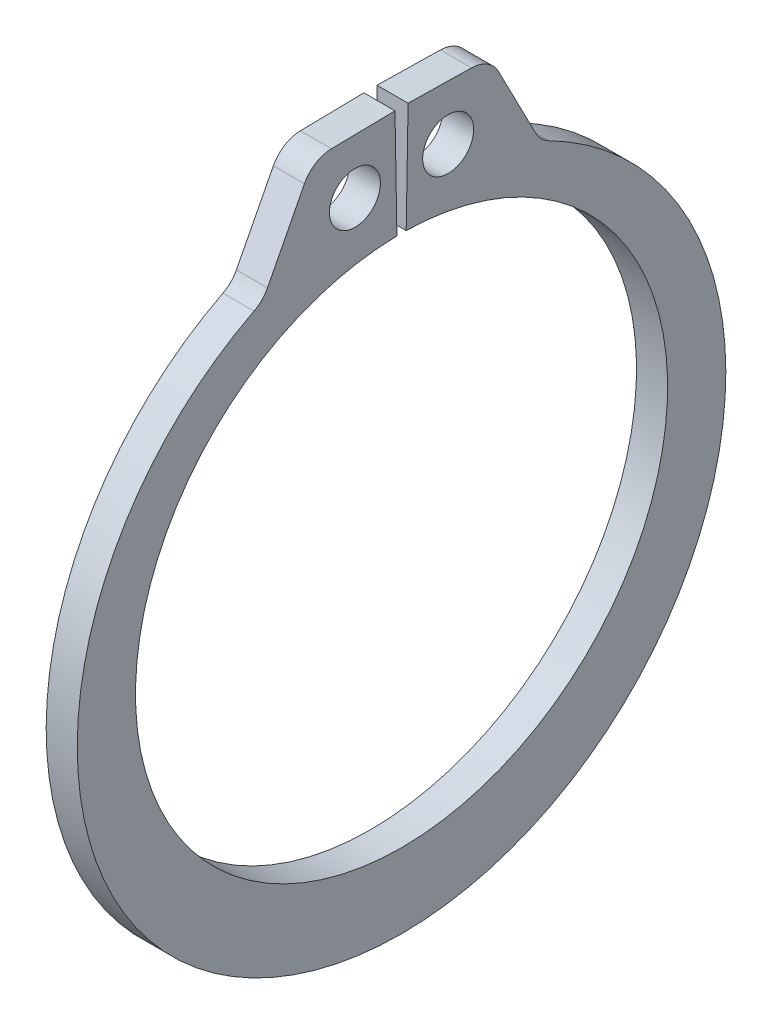
from build123d import *

# Parameters (mm, degrees)
SKETCH1_R      = 0.5207
EXTRUDE1_DEPTH = 0.3175
FILLET1_R      = 0.635


with BuildPart() as part:
    # Sketch1 → Extrude1 (new, symmetric)
    with BuildSketch(Plane(origin=(0, 0, 0), x_dir=(0, 0, -1), z_dir=(1, 0, 0))):
        with BuildLine():
            Line((-0.0948643, 5.434772132), (-0.133873919, 7.6696317))
            Line((-0.133873919, 7.6696317), (-1.810018595, 7.640374486))
            Line((-1.810018595, 7.640374486), (-2.834582122, 5.653822543))
            ThreePointArc((-2.834582122, 5.653822543), (0, -6.9596), (2.834582122, 5.653822543))
            Line((2.834582122, 5.653822543), (1.810018595, 7.640374486))
            Line((1.810018595, 7.640374486), (0.133873919, 7.6696317))
            Line((0.133873919, 7.6696317), (0.0948643, 5.434772132))
            ThreePointArc((0.0948643, 5.434772132), (0, -5.4356), (-0.0948643, 5.434772132))
        make_face()
        with Locations((-0.952441448, 6.537573309)):
            Circle(SKETCH1_R, mode=Mode.SUBTRACT)
        with Locations((0.952441448, 6.537573309)):
            Circle(SKETCH1_R, mode=Mode.SUBTRACT)
    extrude(amount=EXTRUDE1_DEPTH, both=True)

    # Fillet1
    fillet1_edges = [part.edges().sort_by_distance(p)[0] for p in [
        (0, 7.640374486, -1.810018595),
        (0, 5.653822543, -2.834582122),
        (0, 5.653822543, 2.834582122),
        (0, 7.640374486, 1.810018595),
    ]]
    fillet(fillet1_edges, radius=FILLET1_R)


solid = part.part
